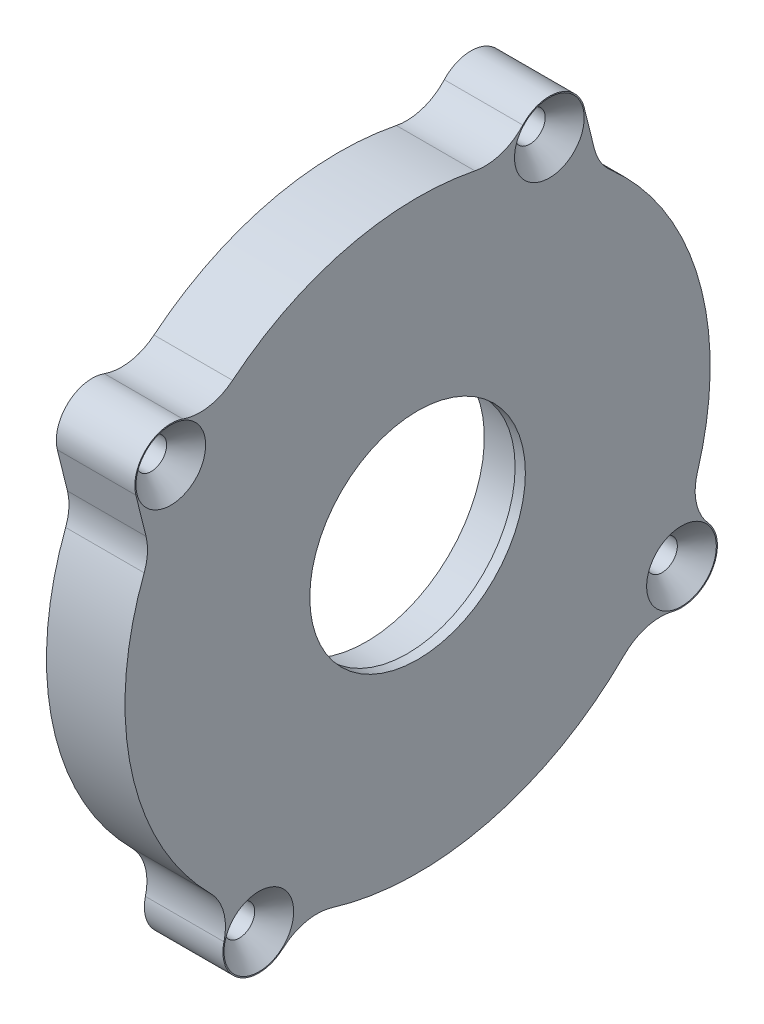
from build123d import *

# Parameters (mm, degrees)
SKETCH1_W           = 3
SKETCH1_H           = 1.5
SKETCH2_R           = 3.5
SKETCH2_R_2         = 1.495
BOSS_EXTRUDE1_DEPTH = 7.65
FILLET1_R           = 5
CHAMFER1_SIZE       = 1.9
BOSS_EXTRUDE2_DEPTH = 7.65
FILLET2_R           = 5


with BuildPart() as part:
    # Sketch1 → Revolve1 (revolve)
    with BuildSketch(Plane.XY):
        Polygon((-6.31640625, 27.5), (-6.31640625, 28.5), (1.33359375, 28.5), (1.33359375, 10.5), (0.33359375, 10.5), (0.33359375, 11.5), (-0.66640625, 11.5), (-0.66640625, 26.5), (-6.81640625, 26.5), (-6.81640625, 27.5), align=None)
        with Locations((-2.16640625, 12.25)):
            Rectangle(SKETCH1_W, SKETCH1_H)
    revolve(axis=Axis((0, 0, 0), (1, 0, 0)))

    # Sketch2 → Boss-Extrude1 (add)
    with BuildSketch(Plane.ZY.offset(6.31640625)):
        with Locations((-12.833666233, 27.116360579)):
            Circle(SKETCH2_R)
        with Locations((-12.833666233, 27.116360579)):
            Circle(SKETCH2_R_2, mode=Mode.SUBTRACT)
        with Locations((24.042513933, 17.943174852)):
            Circle(SKETCH2_R)
        with Locations((24.042513933, 17.943174852)):
            Circle(SKETCH2_R_2, mode=Mode.SUBTRACT)
        with Locations((15.464980443, -25.706699125)):
            Circle(SKETCH2_R)
        with Locations((15.464980443, -25.706699125)):
            Circle(SKETCH2_R_2, mode=Mode.SUBTRACT)
        with Locations((-25.706699125, -15.464980443)):
            Circle(SKETCH2_R)
        with Locations((-25.706699125, -15.464980443)):
            Circle(SKETCH2_R_2, mode=Mode.SUBTRACT)
    extrude(amount=-BOSS_EXTRUDE1_DEPTH)

    # Fillet1
    fillet1_edges = [part.edges().sort_by_distance(p)[0] for p in [
        (-2.49140625, 26.926500874, -9.338819556),
        (-2.49140625, 19.412851347, 20.866029871),
        (-2.49140625, -17.243063028, -22.691998092),
        (-2.49140625, -11.968566697, -25.865100255),
        (-2.49140625, -22.691998092, 17.243063028),
        (-2.49140625, -25.865100255, 11.968566697),
    ]]
    fillet(fillet1_edges, radius=FILLET1_R)

    # Chamfer1
    chamfer1_edges = [part.edges().sort_by_distance(p)[0] for p in [
        (1.33359375, 27.116360579, -14.328666233),
        (1.33359375, 17.943174852, 22.547513933),
        (1.33359375, -15.464980443, -27.201699125),
        (1.33359375, -25.706699125, 13.969980443),
    ]]
    chamfer(chamfer1_edges, length=CHAMFER1_SIZE)

    # Sketch4 → Boss-Extrude2 (add)
    with BuildSketch(Plane.ZY.offset(6.31640625)):
        with BuildLine():
            ThreePointArc((-14.902549995, 24.29329133), (-16.124726175, 25.925174422), (-16.230156511, 27.961259264))
            Line((-16.230156511, 27.961259264), (-17.61181157, 22.407009913))
            ThreePointArc((-17.61181157, 22.407009913), (-16.284515387, 23.38941125), (-14.902549995, 24.29329133))
        make_face()
        with BuildLine():
            Line((26.057349153, 11.544026816), (27.439004212, 17.098276167))
            ThreePointArc((27.439004212, 17.098276167), (26.391913334, 15.34888835), (24.547607559, 14.479812262))
            ThreePointArc((24.547607559, 14.479812262), (25.345021602, 13.033797605), (26.057349153, 11.544026816))
        make_face()
    extrude(amount=-BOSS_EXTRUDE2_DEPTH)

    # Fillet2
    fillet2_edges = [part.edges().sort_by_distance(p)[0] for p in [
        (-2.49140625, 22.407009913, -17.61181157),
        (-2.49140625, 11.544026816, 26.057349153),
    ]]
    fillet(fillet2_edges, radius=FILLET2_R)


solid = part.part
